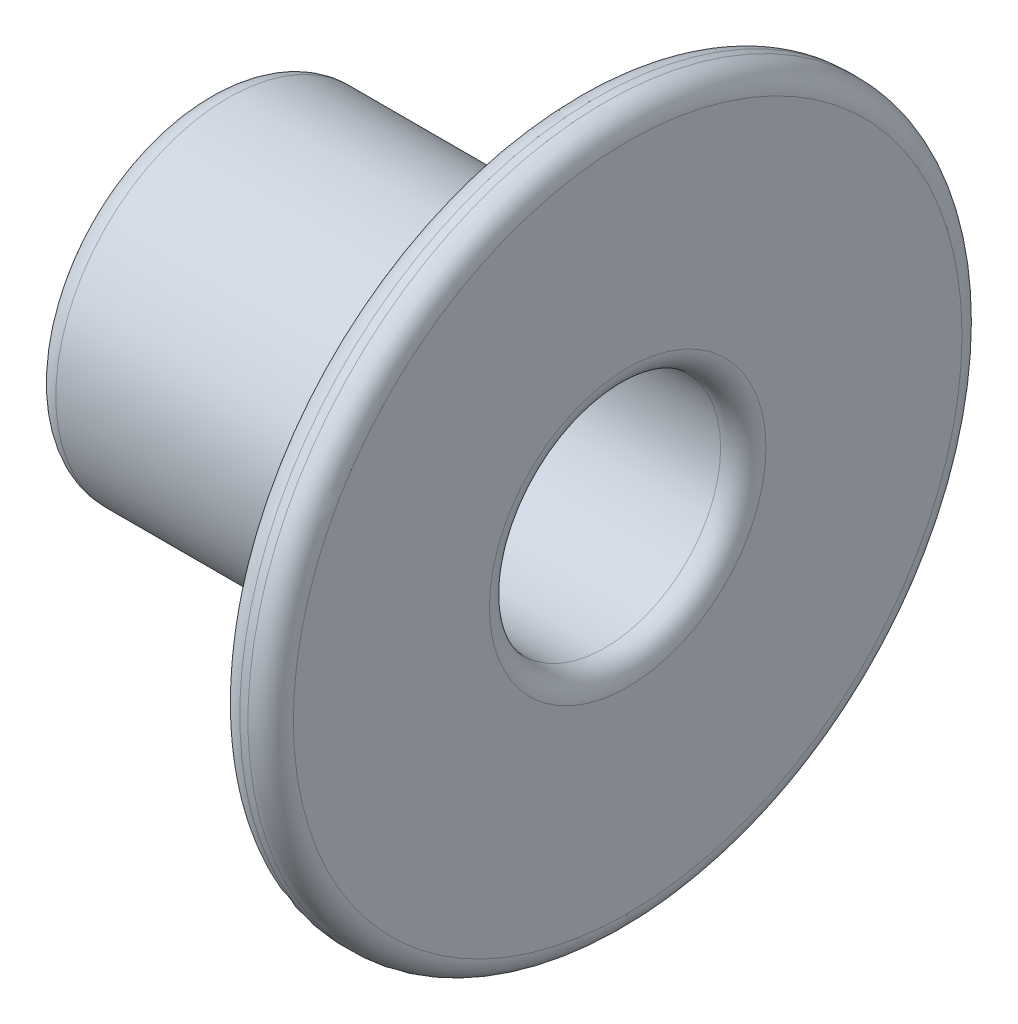
from build123d import *


with BuildPart() as part:
    # 草图1 → 旋转1 (revolve)
    with BuildSketch(Plane.XY):
        with BuildLine():
            Line((-455, 8.382), (-455, 0))
            Line((-455, 0), (-450, 0))
            Line((-450, 0), (-450, 6.477))
            Line((-450, 6.477), (-432.612413979, 6.477))
            ThreePointArc((-432.612413979, 6.477), (-431.714388367, 6.848974388), (-431.342413979, 7.747))
            Line((-431.342413979, 7.747), (-431.342413979, 18.73))
            ThreePointArc((-431.342413979, 18.73), (-431.714388367, 19.628025612), (-432.612413979, 20))
            Line((-432.612413979, 20), (-433.072413979, 20))
            ThreePointArc((-433.072413979, 20), (-433.970439591, 19.628025612), (-434.342413979, 18.73))
            Line((-434.342413979, 18.73), (-434.342413979, 11.652))
            ThreePointArc((-434.342413979, 11.652), (-434.928200417, 10.237786438), (-436.342413979, 9.652))
            Line((-436.342413979, 9.652), (-453.73, 9.652))
            ThreePointArc((-453.73, 9.652), (-454.628025612, 9.280025612), (-455, 8.382))
        make_face()
    revolve(axis=Axis((-455.001250002, 0, 0), (1, 0, 0)))


solid = part.part
